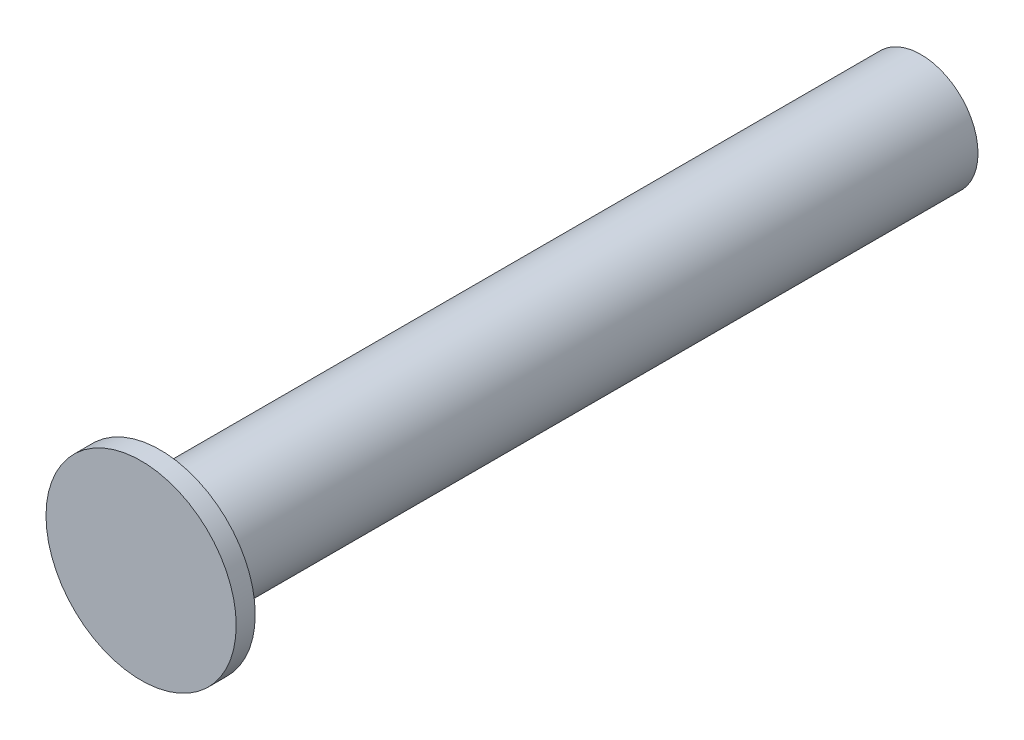
from build123d import *

# Parameters (mm, degrees)
SKETCH_1_R      = 0.3
EXTRUDE_1_DEPTH = 4
SKETCH_2_R      = 0.5
EXTRUDE_2_DEPTH = 0.1


with BuildPart() as part:
    # 草图1 → 凸台-拉伸1 (new body)
    with BuildSketch(Plane.XY):
        Circle(SKETCH_1_R)
    extrude(amount=EXTRUDE_1_DEPTH)

    # 草图2 → 凸台-拉伸2 (add)
    with BuildSketch(Plane.XY.offset(4)):
        Circle(SKETCH_2_R)
    extrude(amount=EXTRUDE_2_DEPTH)


solid = part.part
